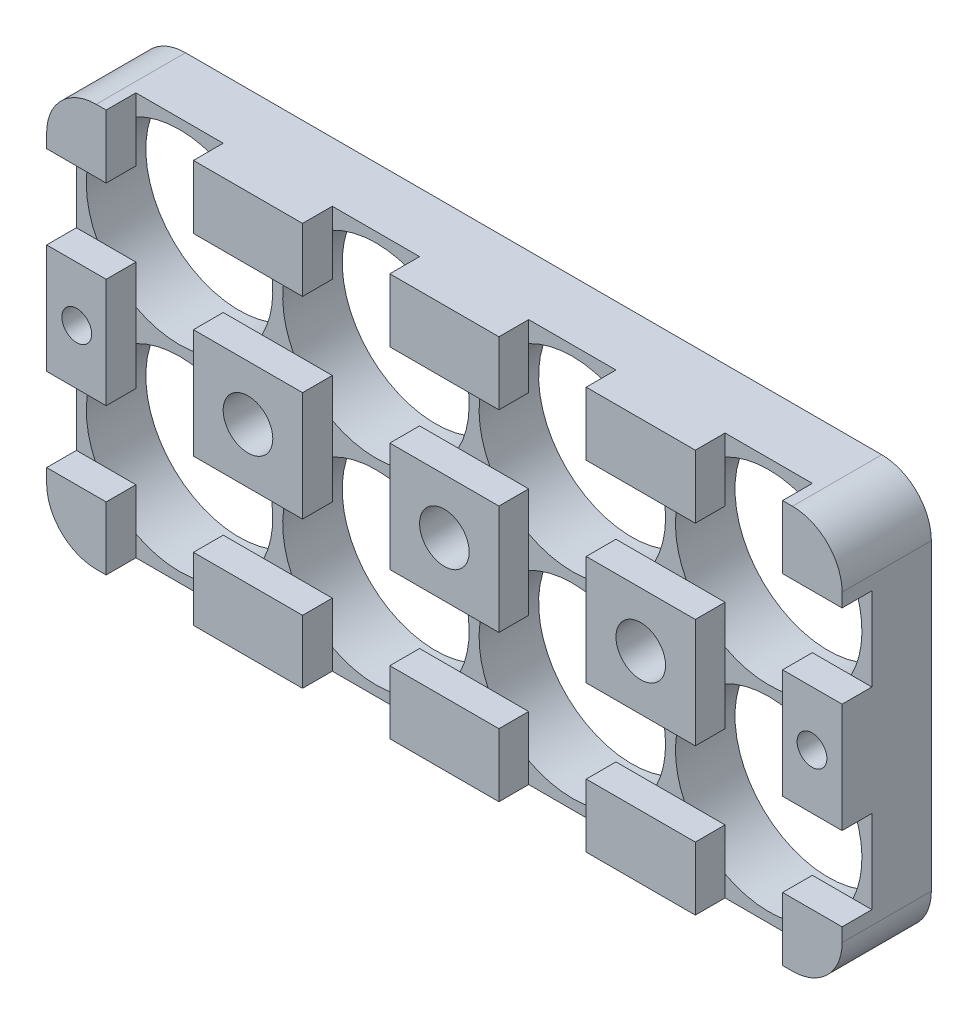
from build123d import *

# Parameters (mm, degrees)
SKETCH_1_W               = 80.2
SKETCH_1_H               = 40.6
SKETCH_1_R               = 9.4
SKETCH_1_R_2             = 2.5
EXTRUDE_1_DEPTH          = 6
SKETCH_2_W               = 80.2
SKETCH_2_H               = 40.6
EXTRUDE_2_DEPTH          = 3
SKETCH_3_W               = 80.2
SKETCH_3_H               = 8.4
CUT_EXTRUDE_1_DEPTH      = 3
SKETCH_4_W               = 8.8
SKETCH_4_H               = 40.6
CUT_EXTRUDE_2_DEPTH      = 3
SKETCH_5_R               = 2.5
SKETCH_5_R_2             = 1.5
CUT_EXTRUDE_3_DEPTH      = 7
CUT_EXTRUDE_3_DEPTH_BACK = 10
FILLET_3_R               = 5
FILLET_8_R               = 5
FILLET_9_R               = 5
FILLET_10_R              = 5


with BuildPart() as part:
    # 草图1 → 凸台-拉伸1 (new body)
    with BuildSketch(Plane.XY):
        with Locations((29.7, -9.9)):
            Rectangle(SKETCH_1_W, SKETCH_1_H)
        Circle(SKETCH_1_R, mode=Mode.SUBTRACT)
        with Locations((19.8, 0)):
            Circle(SKETCH_1_R, mode=Mode.SUBTRACT)
        with Locations((39.6, 0)):
            Circle(SKETCH_1_R, mode=Mode.SUBTRACT)
        with Locations((59.4, 0)):
            Circle(SKETCH_1_R, mode=Mode.SUBTRACT)
        with Locations((0, -19.8)):
            Circle(SKETCH_1_R, mode=Mode.SUBTRACT)
        with Locations((19.8, -19.8)):
            Circle(SKETCH_1_R, mode=Mode.SUBTRACT)
        with Locations((39.6, -19.8)):
            Circle(SKETCH_1_R, mode=Mode.SUBTRACT)
        with Locations((59.4, -19.8)):
            Circle(SKETCH_1_R, mode=Mode.SUBTRACT)
        with Locations((9.9, -9.9)):
            Circle(SKETCH_1_R_2, mode=Mode.SUBTRACT)
        with Locations((29.7, -9.9)):
            Circle(SKETCH_1_R_2, mode=Mode.SUBTRACT)
        with Locations((49.5, -9.9)):
            Circle(SKETCH_1_R_2, mode=Mode.SUBTRACT)
    extrude(amount=EXTRUDE_1_DEPTH)

    # 草图2 → 凸台-拉伸2 (add)
    with BuildSketch(Plane.XY.offset(6)):
        with Locations((29.7, -9.9)):
            Rectangle(SKETCH_2_W, SKETCH_2_H)
    extrude(amount=EXTRUDE_2_DEPTH)

    # 草图3 → 切除-拉伸1 (cut)
    with BuildSketch(Plane.XY.offset(9)):
        with Locations((29.7, -0.18)):
            Rectangle(SKETCH_3_W, SKETCH_3_H)
        with Locations((29.7, -19.62)):
            Rectangle(SKETCH_3_W, SKETCH_3_H)
    extrude(amount=-CUT_EXTRUDE_1_DEPTH, mode=Mode.SUBTRACT)

    # 草图4 → 切除-拉伸2 (cut)
    with BuildSketch(Plane.XY.offset(9)):
        with Locations((0, -9.9)):
            Rectangle(SKETCH_4_W, SKETCH_4_H)
        with Locations((19.8, -9.9)):
            Rectangle(SKETCH_4_W, SKETCH_4_H)
        with Locations((39.6, -9.9)):
            Rectangle(SKETCH_4_W, SKETCH_4_H)
        with Locations((59.4, -9.9)):
            Rectangle(SKETCH_4_W, SKETCH_4_H)
    extrude(amount=-CUT_EXTRUDE_2_DEPTH, mode=Mode.SUBTRACT)

    # 草图5 → 切除-拉伸3 (cut, two sides)
    with BuildSketch(Plane(origin=(0, 0, 6), x_dir=(-1, 0, 0), z_dir=(0, 0, -1))) as cut_extrude_3_sk:
        with Locations((-49.5, -9.9)):
            Circle(SKETCH_5_R)
        with Locations((-29.7, -9.9)):
            Circle(SKETCH_5_R)
        with Locations((-9.9, -9.9)):
            Circle(SKETCH_5_R)
        with Locations((-66.76305517, -9.9)):
            Circle(SKETCH_5_R_2)
        with Locations((7.36305517, -9.9)):
            Circle(SKETCH_5_R_2)
    extrude(amount=CUT_EXTRUDE_3_DEPTH, mode=Mode.SUBTRACT)
    extrude(cut_extrude_3_sk.sketch, amount=-CUT_EXTRUDE_3_DEPTH_BACK, mode=Mode.SUBTRACT)

    # 圆角3
    fillet_3_edges = [part.edges().sort_by_distance(p)[0] for p in [
        (-10.4, -30.2, 4.5),
    ]]
    fillet(fillet_3_edges, radius=FILLET_3_R)

    # 圆角8
    fillet_8_edges = [part.edges().sort_by_distance(p)[0] for p in [
        (69.8, -30.2, 4.5),
    ]]
    fillet(fillet_8_edges, radius=FILLET_8_R)

    # 圆角9
    fillet_9_edges = [part.edges().sort_by_distance(p)[0] for p in [
        (69.8, 10.4, 4.5),
    ]]
    fillet(fillet_9_edges, radius=FILLET_9_R)

    # 圆角10
    fillet_10_edges = [part.edges().sort_by_distance(p)[0] for p in [
        (-10.4, 10.4, 4.5),
    ]]
    fillet(fillet_10_edges, radius=FILLET_10_R)


solid = part.part
